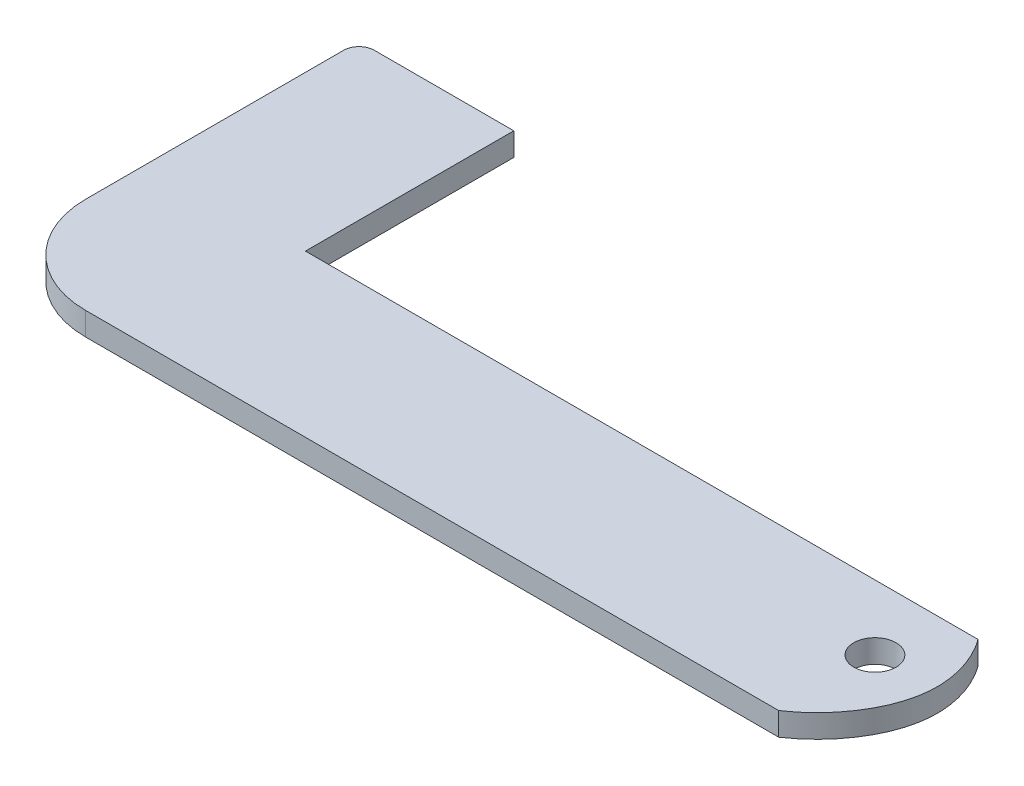
from build123d import *

# Parameters (mm, degrees)
SKETCH1_R           = 2.75
BOSS_EXTRUDE6_DEPTH = 3


with BuildPart() as part:
    # Sketch1 → Boss-Extrude6 (new body)
    with BuildSketch(Plane(origin=(0, 0, 0), x_dir=(1, 0, 0), z_dir=(0, 1, 0))):
        with BuildLine():
            Line((-45, -12.5), (45, -12.5))
            add(Edge.make_bspline(
                [(49.941104818, 8.442089367), (50.270924983, 7.993844293), (51.917772, 5.447061543), (54.055554594, -2.684937186), (49.028319605, -9.822821411), (45, -12.5)],
                knots=[0.210171728, 0.210171728, 0.210171728, 0.210171728, 0.264235121, 0.503984815, 1, 1, 1, 1], degree=3))
            Line((49.941104818, 8.442089367), (-37.395508702, 8.442089367))
            Line((-37.395508702, 8.442089367), (-37.395508702, 35.5))
            Line((-37.395508702, 35.5), (-55.5, 35.5))
            ThreePointArc((-55.5, 35.5), (-56.914213562, 34.914213562), (-57.5, 33.5))
            Line((-57.5, 33.5), (-57.5, 0))
            ThreePointArc((-57.5, 0), (-53.838834765, -8.838834765), (-45, -12.5))
        make_face()
        with Locations((45, 0)):
            Circle(SKETCH1_R, mode=Mode.SUBTRACT)
    extrude(amount=BOSS_EXTRUDE6_DEPTH)


solid = part.part
